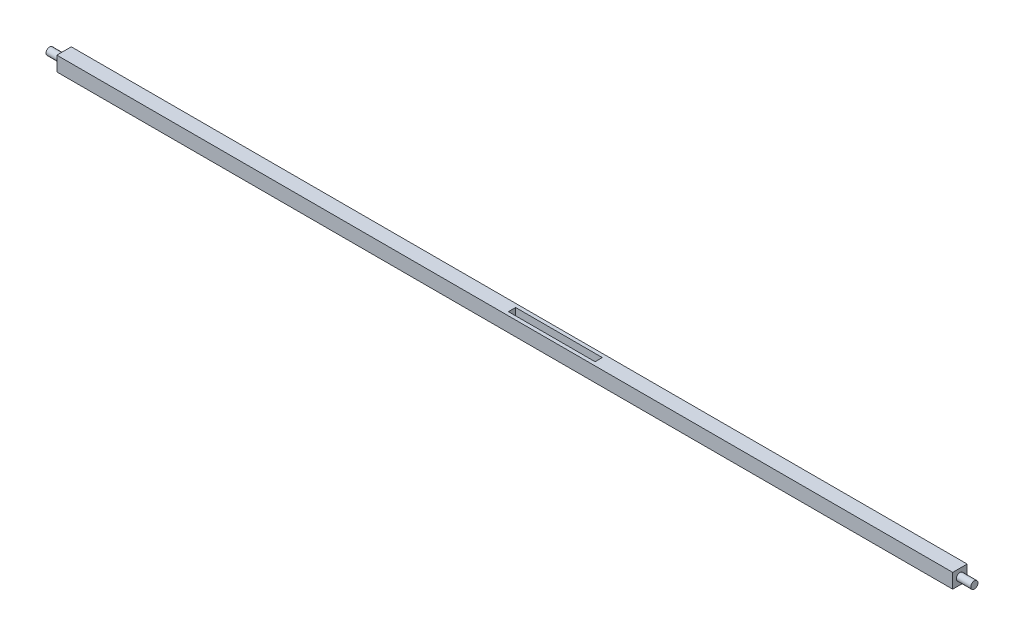
from build123d import *

# Parameters (mm, degrees)
SKETCH1_W          = 12.7
SKETCH1_H          = 12.82133758
LENGTH_DEPTH       = 406.4
SKETCH2_W          = 12.7
SKETCH2_H          = 12.82133758
SKETCH2_R          = 3.175
ROUND_CUT_1_DEPTH  = 12.7
SKETCH3_W          = 12.7
SKETCH3_H          = 12.82133758
SKETCH3_R          = 3.175
ROUND_CUT_2_DEPTH  = 12.7
CUT_EXTRUDE1_REACH = 14.821
SKETCH5_W          = 76.2
SKETCH5_H          = 6.35


with BuildPart() as part:
    # Sketch1 → Length (new body, symmetric)
    with BuildSketch(Plane(origin=(0, 0, 0), x_dir=(0, 0, -1), z_dir=(1, 0, 0))):
        Rectangle(SKETCH1_W, SKETCH1_H)
    extrude(amount=LENGTH_DEPTH, both=True)

    # Sketch2 → Round Cut 1 (cut)
    with BuildSketch(Plane(origin=(406.4, 0, 0), x_dir=(0, 0, -1), z_dir=(1, 0, 0))):
        Rectangle(SKETCH2_W, SKETCH2_H)
        Circle(SKETCH2_R, mode=Mode.SUBTRACT)
    extrude(amount=-ROUND_CUT_1_DEPTH, mode=Mode.SUBTRACT)

    # Sketch3 → Round Cut 2 (cut)
    with BuildSketch(Plane.ZY.offset(406.4)):
        Rectangle(SKETCH3_W, SKETCH3_H)
        Circle(SKETCH3_R, mode=Mode.SUBTRACT)
    extrude(amount=-ROUND_CUT_2_DEPTH, mode=Mode.SUBTRACT)

    # Sketch5 → Cut-Extrude1 (cut, up to next)
    with BuildSketch(Plane(origin=(0, 6.41066879, 0), x_dir=(1, 0, 0), z_dir=(0, 1, 0)), mode=Mode.PRIVATE) as cut_extrude1_sk1:
        with Locations((38.1, 0)):
            Rectangle(SKETCH5_W, SKETCH5_H)
    cut_extrude1_tool1 = extrude(cut_extrude1_sk1.sketch, amount=-CUT_EXTRUDE1_REACH, mode=Mode.PRIVATE) & part.part
    add(cut_extrude1_tool1.solids().sort_by_distance((38.1, 6.410669, 0))[0], mode=Mode.SUBTRACT)


solid = part.part
